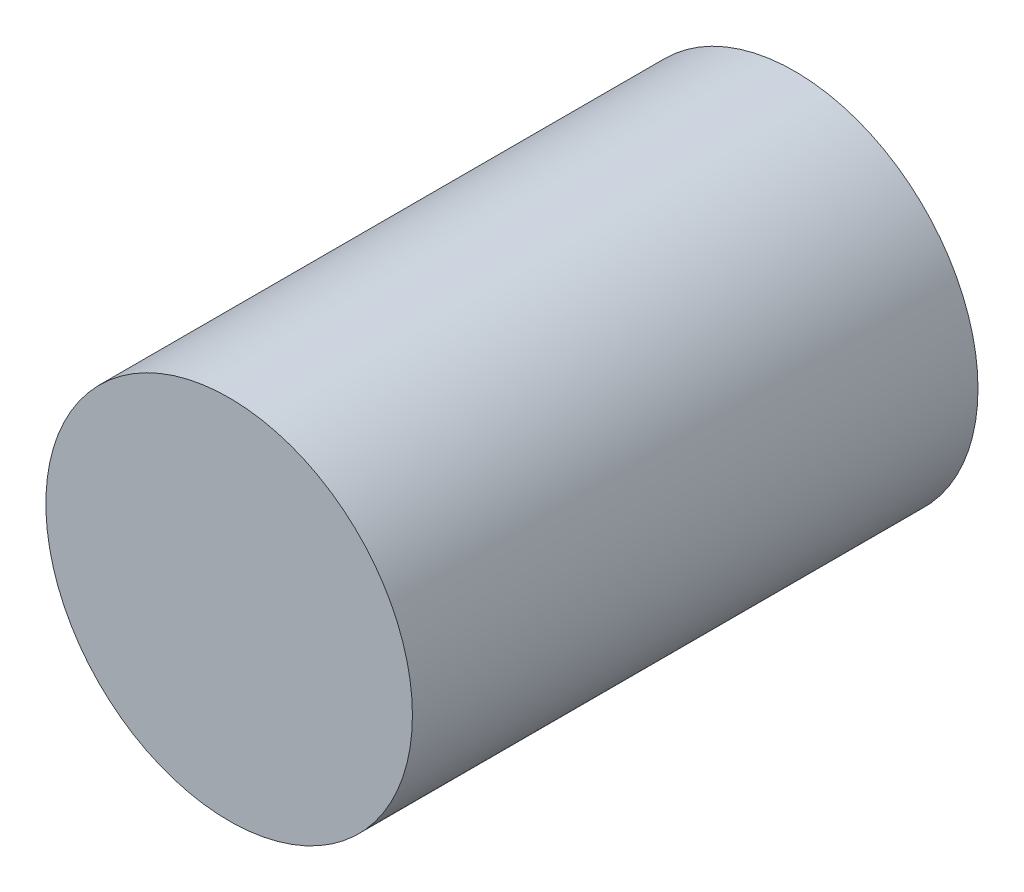
from build123d import *

# Parameters (mm, degrees)
SKETCH1_R      = 16.4465
EXTRUDE1_DEPTH = 50.7492


with BuildPart() as part:
    # Sketch1 → Extrude1 (new body)
    with BuildSketch(Plane.XY):
        Circle(SKETCH1_R)
    extrude(amount=EXTRUDE1_DEPTH)


solid = part.part
